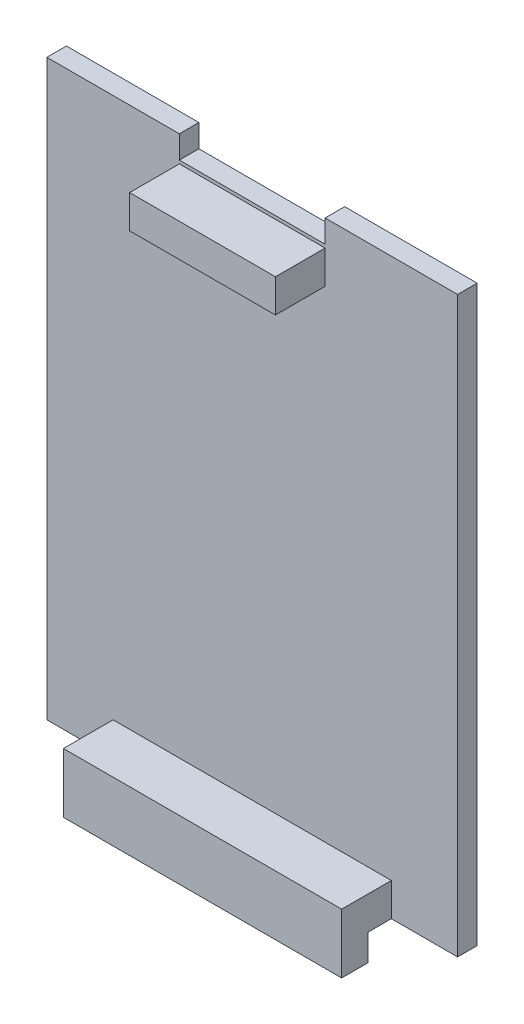
from build123d import *

# Parameters (mm, degrees)
SKETCH1_W           = 31.5
SKETCH1_H           = 44
BOSS_EXTRUDE1_DEPTH = 1.5
SKETCH2_W           = 11.18
SKETCH2_H           = 2.54
BOSS_EXTRUDE2_DEPTH = 3.81
SKETCH4_W           = 11.18
SKETCH4_H           = 1.746
CUT_EXTRUDE1_DEPTH  = 3.81
SKETCH5_W           = 21.34
SKETCH5_H           = 2.54
BOSS_EXTRUDE3_DEPTH = 3.81
SKETCH8_W           = 21.34
SKETCH8_H           = 2.032
BOSS_EXTRUDE4_DEPTH = 2.032


with BuildPart() as part:
    # Sketch1 → Boss-Extrude1 (new body)
    with BuildSketch(Plane.XY):
        with Locations((13.046077502, 22)):
            Rectangle(SKETCH1_W, SKETCH1_H)
    extrude(amount=BOSS_EXTRUDE1_DEPTH)

    # Sketch2 → Boss-Extrude2 (add)
    with BuildSketch(Plane.XY.offset(1.5)):
        with Locations((13.046077502, 40.73)):
            Rectangle(SKETCH2_W, SKETCH2_H)
    extrude(amount=BOSS_EXTRUDE2_DEPTH)

    # Sketch4 → Cut-Extrude1 (cut)
    with BuildSketch(Plane.XY.offset(1.5)):
        with Locations((13.046077502, 43.127)):
            Rectangle(SKETCH4_W, SKETCH4_H)
    extrude(amount=-CUT_EXTRUDE1_DEPTH, mode=Mode.SUBTRACT)

    # Sketch5 → Boss-Extrude3 (add)
    with BuildSketch(Plane.XY.offset(1.5)):
        with Locations((13.046077502, 1.27)):
            Rectangle(SKETCH5_W, SKETCH5_H)
    extrude(amount=BOSS_EXTRUDE3_DEPTH)

    # Sketch8 → Boss-Extrude4 (add)
    with BuildSketch(Plane(origin=(0, 0, 0), x_dir=(-1, 0, 0), z_dir=(0, -1, 0))):
        with Locations((-13.046077502, -4.294)):
            Rectangle(SKETCH8_W, SKETCH8_H)
    extrude(amount=BOSS_EXTRUDE4_DEPTH)


solid = part.part
